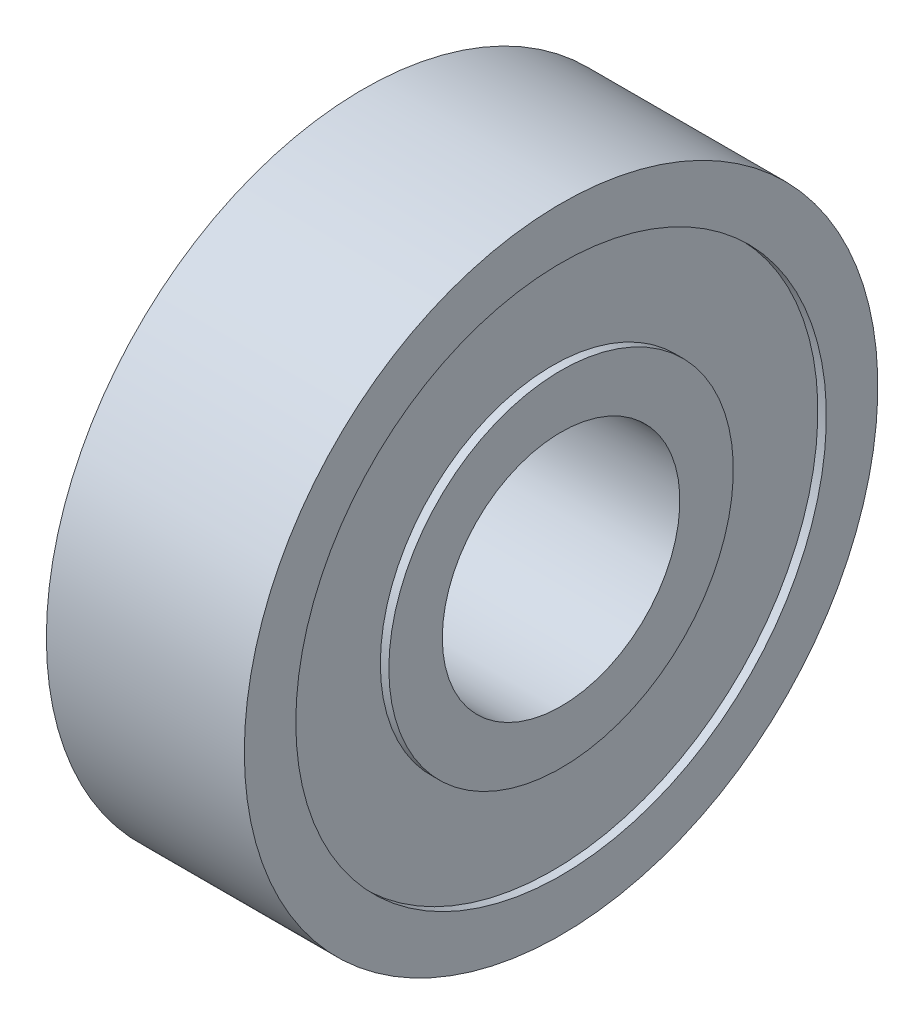
from build123d import *


with BuildPart() as part:
    # ｽｹｯﾁ1 → 回転1 (revolve)
    with BuildSketch(Plane.XY):
        Polygon((0, 13.4), (0.43, 13.4), (0.43, 8.7), (0, 8.7), (0, 6), (10, 6), (10, 8.7), (9.57, 8.7), (9.57, 13.4), (10, 13.4), (10, 16), (0, 16), align=None)
    revolve(axis=Axis((50, 0, 0), (-1, 0, 0)))


solid = part.part
